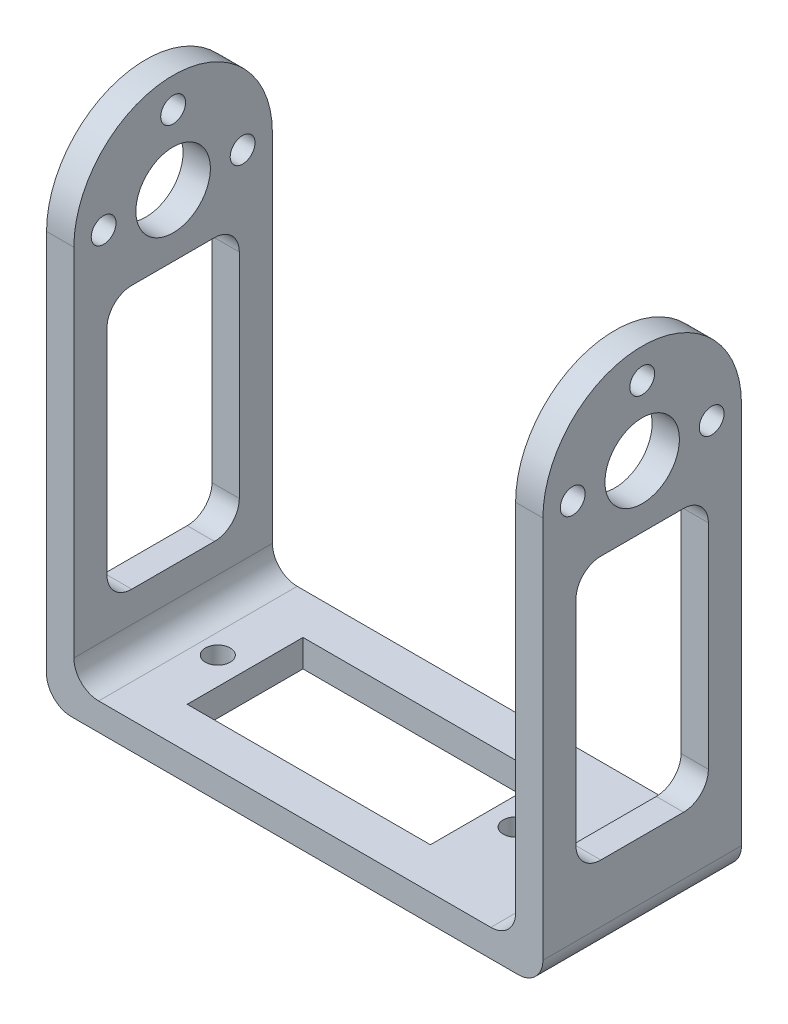
from build123d import *

# Parameters (mm, degrees)
SKETCH1_W           = 60
SKETCH1_H           = 24
BOSS_EXTRUDE1_DEPTH = 3.3
SKETCH2_W           = 3.3
SKETCH2_H           = 24
BOSS_EXTRUDE2_DEPTH = 61.3
SKETCH3_W           = 16
SKETCH3_H           = 31.8
CUT_EXTRUDE1_DEPTH  = 3.3
CUT_EXTRUDE2_DEPTH  = 3.3
SKETCH5_R           = 4.5
SKETCH5_R_2         = 1.5
CUT_EXTRUDE3_DEPTH  = 3.3
SKETCH7_R           = 1.5
SKETCH7_W           = 29.4
SKETCH7_H           = 14
CUT_EXTRUDE4_DEPTH  = 3.3
FILLET1_R           = 3


with BuildPart() as part:
    # Sketch1 → Boss-Extrude1 (new body)
    with BuildSketch(Plane(origin=(0, 0, 0), x_dir=(1, 0, 0), z_dir=(0, 1, 0))):
        Rectangle(SKETCH1_W, SKETCH1_H)
    extrude(amount=BOSS_EXTRUDE1_DEPTH)

    # Sketch2 → Boss-Extrude2 (add)
    with BuildSketch(Plane(origin=(0, 0, 0), x_dir=(1, 0, 0), z_dir=(0, 1, 0))):
        with Locations((28.35, 0)):
            Rectangle(SKETCH2_W, SKETCH2_H)
    boss_extrude2 = extrude(amount=BOSS_EXTRUDE2_DEPTH)

    # Sketch3 → Cut-Extrude1 (cut)
    with BuildSketch(Plane(origin=(30, 0, 0), x_dir=(0, 0, -1), z_dir=(1, 0, 0))):
        with Locations((0, 25.9)):
            Rectangle(SKETCH3_W, SKETCH3_H)
    cut_extrude1 = extrude(amount=-CUT_EXTRUDE1_DEPTH, mode=Mode.SUBTRACT)

    # Sketch4 → Cut-Extrude2 (cut)
    with BuildSketch(Plane(origin=(30, 0, 0), x_dir=(0, 0, -1), z_dir=(1, 0, 0))):
        with BuildLine():
            ThreePointArc((2.4e-08, 61.3), (8.485281383, 57.785281366), (12, 49.3))
            Line((12, 49.3), (12, 61.3))
            Line((12, 61.3), (2.4e-08, 61.3))
        make_face()
        with BuildLine():
            ThreePointArc((-12, 49.3), (-8.485281366, 57.785281383), (2.4e-08, 61.3))
            Line((2.4e-08, 61.3), (-12, 61.3))
            Line((-12, 61.3), (-12, 49.3))
        make_face()
    cut_extrude2 = extrude(amount=-CUT_EXTRUDE2_DEPTH, mode=Mode.SUBTRACT)

    # Sketch5 → Cut-Extrude3 (cut)
    with BuildSketch(Plane(origin=(30, 0, 0), x_dir=(0, 0, -1), z_dir=(1, 0, 0))):
        with Locations((0, 49.3)):
            Circle(SKETCH5_R)
        with Locations((8.4, 49.3)):
            Circle(SKETCH5_R_2)
        with Locations((0, 57.7)):
            Circle(SKETCH5_R_2)
        with Locations((-8.4, 49.3)):
            Circle(SKETCH5_R_2)
    cut_extrude3 = extrude(amount=-CUT_EXTRUDE3_DEPTH, mode=Mode.SUBTRACT)

    # Sketch7 → Cut-Extrude4 (cut)
    with BuildSketch(Plane(origin=(0, 0, 0), x_dir=(1, 0, 0), z_dir=(0, 1, 0))):
        with Locations((-21.3, 0)):
            Circle(SKETCH7_R)
        with Locations((14.7, 0)):
            Circle(SKETCH7_R)
        with Locations((-3.3, 0)):
            Rectangle(SKETCH7_W, SKETCH7_H)
    extrude(amount=CUT_EXTRUDE4_DEPTH, mode=Mode.SUBTRACT)

    # Mirror2: Boss-Extrude2, Cut-Extrude1, Cut-Extrude2, Cut-Extrude3 across plane
    add(boss_extrude2.mirror(Plane(origin=(0, 0, 0), x_dir=(0, 0, 1), z_dir=(1, 0, 0))))
    add(cut_extrude1.mirror(Plane(origin=(0, 0, 0), x_dir=(0, 0, 1), z_dir=(1, 0, 0))), mode=Mode.SUBTRACT)
    add(cut_extrude2.mirror(Plane(origin=(0, 0, 0), x_dir=(0, 0, 1), z_dir=(1, 0, 0))), mode=Mode.SUBTRACT)
    add(cut_extrude3.mirror(Plane(origin=(0, 0, 0), x_dir=(0, 0, 1), z_dir=(1, 0, 0))), mode=Mode.SUBTRACT)

    # Fillet1
    fillet1_edges = [part.edges().sort_by_distance(p)[0] for p in [
        (-26.7, 3.3, 0),
        (-28.35, 10, 8),
        (-28.35, 41.8, 8),
        (-28.35, 41.8, -8),
        (-28.35, 10, -8),
        (26.7, 3.3, 0),
        (28.35, 41.8, -8),
        (28.35, 10, -8),
        (28.35, 10, 8),
        (28.35, 41.8, 8),
        (-30, 0, 0),
        (30, 0, 0),
    ]]
    fillet(fillet1_edges, radius=FILLET1_R)


solid = part.part
